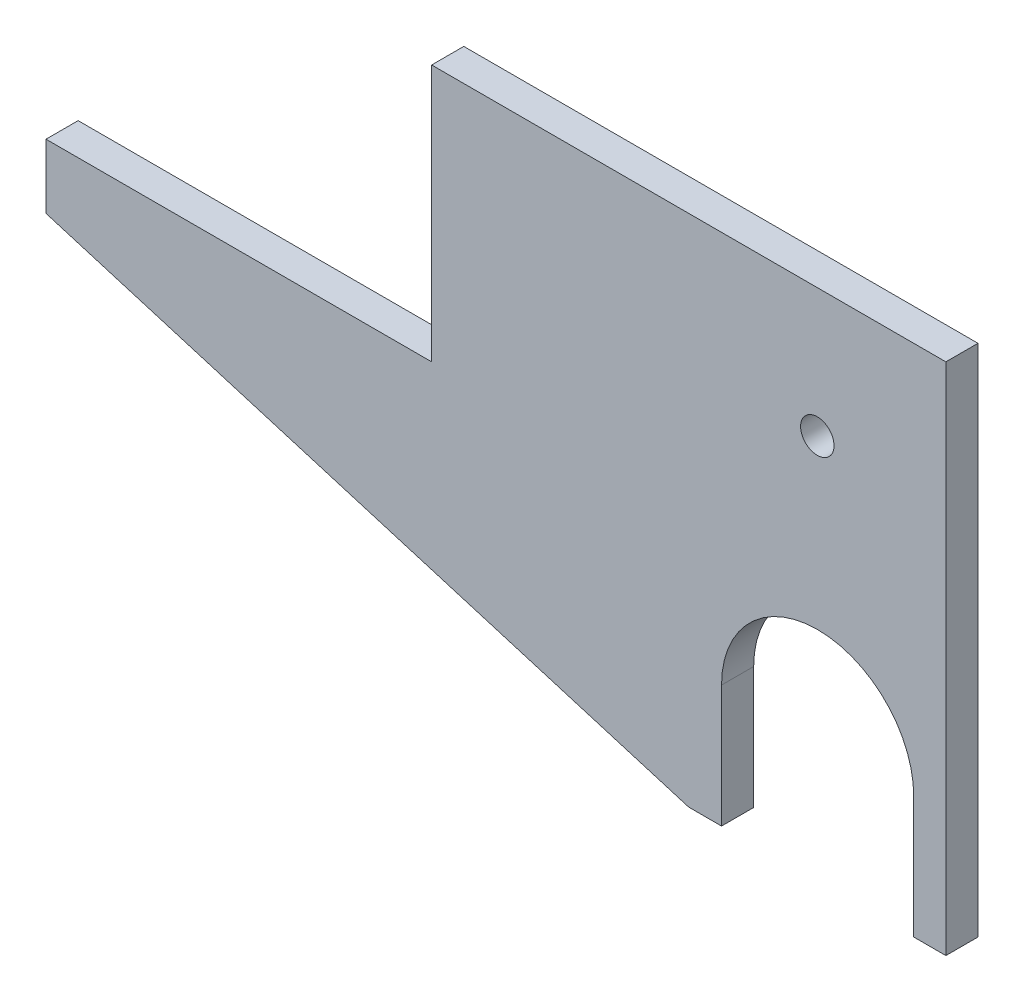
from build123d import *

# Parameters (mm, degrees)
BOSS_EXTRUDE1_DEPTH = 6.35
SKETCH2_R           = 3.302
CUT_EXTRUDE3_DEPTH  = 6.35


with BuildPart() as part:
    # Sketch1 → Boss-Extrude1 (new body)
    with BuildSketch(Plane.XY):
        with BuildLine():
            Line((914.4, 0), (838.2, 0))
            Line((838.2, 0), (838.2, -12.7))
            Line((838.2, -12.7), (965.2, -50.8))
            Line((965.2, -50.8), (971.677, -50.8))
            Line((971.677, -50.8), (971.677, -26.67))
            ThreePointArc((971.677, -26.67), (990.6635, -7.6835), (1009.65, -26.67))
            Line((1009.65, -26.67), (1009.65, -50.8))
            Line((1009.65, -50.8), (1016, -50.8))
            Line((1016, -50.8), (1016, 50.8))
            Line((1016, 50.8), (965.2, 50.8))
            Line((965.2, 50.8), (914.4, 50.8))
            Line((914.4, 50.8), (914.4, 0))
        make_face()
    extrude(amount=BOSS_EXTRUDE1_DEPTH)

    # Sketch2 → Cut-Extrude3 (cut)
    with BuildSketch(Plane.XY.offset(6.35)):
        with Locations((990.6, 25.4)):
            Circle(SKETCH2_R)
    extrude(amount=-CUT_EXTRUDE3_DEPTH, mode=Mode.SUBTRACT)


solid = part.part
